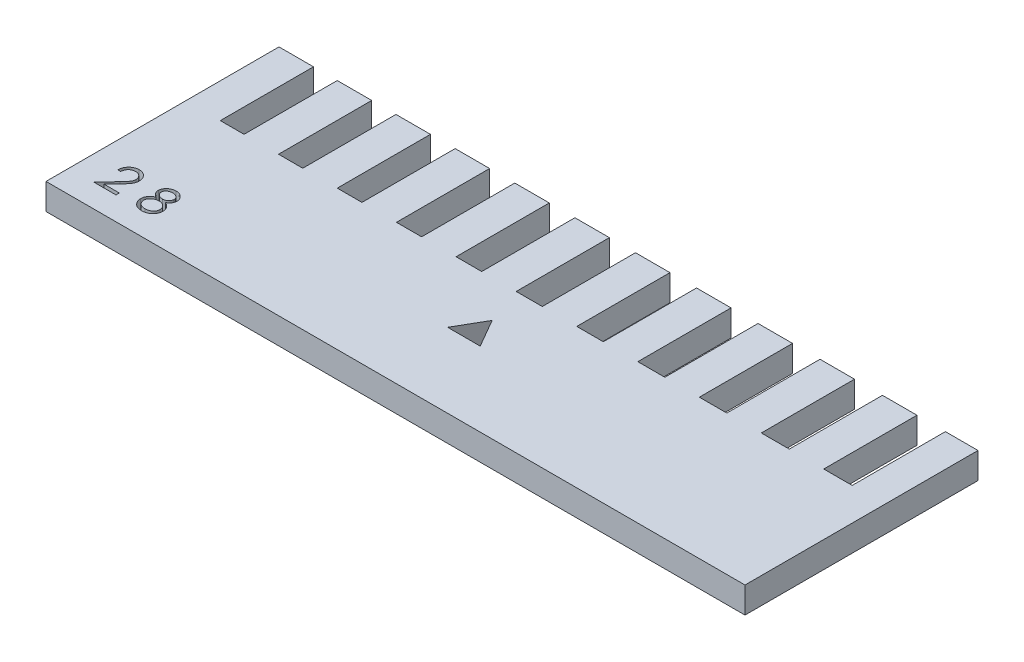
from build123d import *

# Parameters (mm, degrees)
SKETCH1_W           = 75
SKETCH1_H           = 25
BOSS_EXTRUDE1_DEPTH = 2.8
SKETCH2_W           = 2.55
SKETCH2_H           = 10
SKETCH2_W_2         = 2.6
SKETCH2_W_3         = 2.65
SKETCH2_W_4         = 2.7
SKETCH2_W_5         = 2.75
SKETCH2_W_6         = 2.8
SKETCH2_W_7         = 2.85
SKETCH2_W_8         = 2.9
SKETCH2_W_9         = 2.95
SKETCH2_W_10        = 3
SKETCH2_W_11        = 3.05
CUT_EXTRUDE1_DEPTH  = 3.8
CUT_EXTRUDE2_DEPTH  = 2.8
CUT_EXTRUDE4_DEPTH  = 2.8


with BuildPart() as part:
    # Sketch1 → Boss-Extrude1 (new body)
    with BuildSketch(Plane(origin=(0, 0, 0), x_dir=(1, 0, 0), z_dir=(0, 1, 0))):
        with Locations((37.5, 12.5)):
            Rectangle(SKETCH1_W, SKETCH1_H)
    extrude(amount=BOSS_EXTRUDE1_DEPTH)

    # Sketch2 → Cut-Extrude1 (cut, through all)
    with BuildSketch(Plane(origin=(0, 2.8, 0), x_dir=(1, 0, 0), z_dir=(0, 1, 0))):
        with Locations((4.975, 20)):
            Rectangle(SKETCH2_W, SKETCH2_H)
        with Locations((11.25, 20)):
            Rectangle(SKETCH2_W_2, SKETCH2_H)
        with Locations((17.575, 20)):
            Rectangle(SKETCH2_W_3, SKETCH2_H)
        with Locations((23.95, 20)):
            Rectangle(SKETCH2_W_4, SKETCH2_H)
        with Locations((30.375, 20)):
            Rectangle(SKETCH2_W_5, SKETCH2_H)
        with Locations((36.85, 20)):
            Rectangle(SKETCH2_W_6, SKETCH2_H)
        with Locations((43.375, 20)):
            Rectangle(SKETCH2_W_7, SKETCH2_H)
        with Locations((49.95, 20)):
            Rectangle(SKETCH2_W_8, SKETCH2_H)
        with Locations((56.575, 20)):
            Rectangle(SKETCH2_W_9, SKETCH2_H)
        with Locations((63.25, 20)):
            Rectangle(SKETCH2_W_10, SKETCH2_H)
        with Locations((69.975, 20)):
            Rectangle(SKETCH2_W_11, SKETCH2_H)
    extrude(amount=-CUT_EXTRUDE1_DEPTH, mode=Mode.SUBTRACT)

    # Sketch3 → Cut-Extrude2 (cut)
    with BuildSketch(Plane(origin=(0, 2.8, 0), x_dir=(1, 0, 0), z_dir=(0, 1, 0))):
        Polygon((36.85, 11.020725942), (35.1, 7.989637029), (38.6, 7.989637029), align=None)
    extrude(amount=-CUT_EXTRUDE2_DEPTH, mode=Mode.SUBTRACT)

    # Sketch5 → Cut-Extrude4 (cut)
    with BuildSketch(Plane(origin=(0, 2.8, 0), x_dir=(1, 0, 0), z_dir=(0, 1, 0))):
        with BuildLine():
            Line((3.083333333, 4.923076923), (2.769230769, 4.923076923))
            add(Edge.make_bspline(
                [(2.769230769, 4.923076923), (2.771277922, 4.964747811), (2.775298476, 5.046588325), (2.794126766, 5.165912232), (2.821067643, 5.279967031), (2.859159097, 5.387836945), (2.906465375, 5.490475752), (2.963195402, 5.587475767), (3.030389252, 5.678466956), (3.106595986, 5.762605799), (3.189364626, 5.83979337), (3.278670565, 5.906448613), (3.372515592, 5.962766284), (3.470614991, 6.009847526), (3.574075555, 6.045187372), (3.681958413, 6.071409012), (3.794737549, 6.087185357), (3.871577571, 6.088881143), (3.910657051, 6.08974359)],
                knots=[0, 0, 0, 0, 1.10065271, 2.161652631, 3.183658789, 4.190468796, 5.17591951, 6.163126047, 7.15150782, 8.156236427, 9.156009102, 10.134482811, 11.092018607, 12.041330605, 13.001268258, 13.972401359, 14.968799086, 16, 16, 16, 16], degree=3))
            add(Edge.make_bspline(
                [(3.910657051, 6.08974359), (3.949035125, 6.088845133), (4.02444667, 6.087079698), (4.134508684, 6.071918669), (4.239285979, 6.048173078), (4.338573745, 6.014857661), (4.43157981, 5.970073234), (4.519002855, 5.916275695), (4.601883665, 5.854055864), (4.676490449, 5.78080205), (4.744998528, 5.702599666), (4.804100783, 5.619111762), (4.854713947, 5.532882477), (4.896901627, 5.443254275), (4.927957766, 5.349383247), (4.951535974, 5.252636044), (4.964863387, 5.152011233), (4.966908811, 5.083904677), (4.967948718, 5.049278846)],
                knots=[0, 0, 0, 0, 1.111607364, 2.184268762, 3.212621178, 4.221274766, 5.211760367, 6.196651075, 7.1921475, 8.207485113, 9.220403448, 10.201281604, 11.166441695, 12.114753415, 13.065576456, 14.026450734, 14.996634279, 16, 16, 16, 16], degree=3))
            add(Edge.make_bspline(
                [(4.967948718, 5.049278846), (4.966255455, 5.000531012), (4.962898644, 4.903890798), (4.934184267, 4.761875935), (4.889337756, 4.624282516), (4.835340399, 4.513545214), (4.780867955, 4.42431172), (4.731780448, 4.350843015), (4.674315637, 4.271737547), (4.607637139, 4.18726021), (4.533124266, 4.096749304), (4.450102103, 4.000259509), (4.357978621, 3.898787739), (4.29332012, 3.829482138), (4.259815705, 3.793569712)],
                knots=[0, 0, 0, 0, 1.184426356, 2.348067706, 3.509069118, 4.696110526, 5.333549288, 6.050745305, 6.844228056, 7.710549037, 8.667450064, 9.695053472, 10.805634456, 12, 12, 12, 12], degree=3))
            Line((4.259815705, 3.793569712), (3.384114583, 2.858974359))
            Line((3.384114583, 2.858974359), (5.012820513, 2.858974359))
            Line((5.012820513, 2.858974359), (5.012820513, 2.5))
            Line((5.012820513, 2.5), (2.634615385, 2.5))
            Line((2.634615385, 2.5), (3.991987179, 3.948517628))
            add(Edge.make_bspline(
                [(3.991987179, 3.948517628), (4.025035066, 3.983015935), (4.088513293, 4.049280121), (4.17829587, 4.146023081), (4.258934859, 4.235772622), (4.330952251, 4.318359171), (4.392785757, 4.394990738), (4.447657989, 4.463185442), (4.49162358, 4.525939892), (4.539338975, 4.598680506), (4.585552957, 4.687492823), (4.625265313, 4.796026513), (4.649480161, 4.907753765), (4.652384997, 4.983255802), (4.653846154, 5.021233974)],
                knots=[0, 0, 0, 0, 1.329631726, 2.553950428, 3.673215718, 4.687767853, 5.603093632, 6.413772471, 7.123043292, 7.734684054, 8.834405432, 9.900288307, 10.943827018, 12, 12, 12, 12], degree=3))
            add(Edge.make_bspline(
                [(4.653846154, 5.021233974), (4.653210412, 5.045115373), (4.651957486, 5.092181023), (4.640899788, 5.161186782), (4.624189282, 5.227751596), (4.600244024, 5.292080215), (4.568637284, 5.353525867), (4.530163904, 5.412163347), (4.48577384, 5.468852313), (4.434422571, 5.522005611), (4.378011051, 5.570686816), (4.318416802, 5.613810902), (4.255366698, 5.649850012), (4.189126575, 5.679393509), (4.119881106, 5.702568891), (4.047496361, 5.71862747), (3.972172345, 5.728709954), (3.920738849, 5.730074126), (3.89453125, 5.730769231)],
                knots=[0, 0, 0, 0, 0.991446411, 1.95395049, 2.89581595, 3.838931463, 4.798493298, 5.75982156, 6.748411868, 7.785213223, 8.824556874, 9.840280684, 10.836137867, 11.835679398, 12.848801643, 13.863922112, 14.911575587, 16, 16, 16, 16], degree=3))
            add(Edge.make_bspline(
                [(3.89453125, 5.730769231), (3.867160417, 5.730054199), (3.813408621, 5.728649993), (3.734489588, 5.718827329), (3.659203811, 5.701881489), (3.587361908, 5.678704814), (3.518842322, 5.649246266), (3.453978278, 5.612554521), (3.392915389, 5.568771028), (3.335538865, 5.519130471), (3.282674886, 5.46386287), (3.23622801, 5.402252907), (3.195643996, 5.335425492), (3.160234763, 5.263560941), (3.131479073, 5.186007161), (3.109505922, 5.103039456), (3.092119075, 5.015018075), (3.086310555, 4.95423299), (3.083333333, 4.923076923)],
                knots=[0, 0, 0, 0, 1.031018746, 2.02475058, 2.990194455, 3.934040569, 4.864654155, 5.795059489, 6.735614925, 7.690564532, 8.649604399, 9.611025574, 10.590972636, 11.591080095, 12.624614302, 13.701020113, 14.821632451, 16, 16, 16, 16], degree=3))
        make_face()
        with BuildLine():
            add(Edge.make_bspline(
                [(8.374699519, 4.449819712), (8.403348066, 4.434881756), (8.459222301, 4.405747753), (8.538799509, 4.358836925), (8.61152451, 4.30939596), (8.679415072, 4.259760101), (8.741278423, 4.208028449), (8.796422836, 4.153995293), (8.846210456, 4.099009348), (8.88963724, 4.042139508), (8.927834077, 3.983536859), (8.960846212, 3.923047586), (8.989063415, 3.860804252), (9.011426353, 3.796127422), (9.029848145, 3.72996716), (9.04252375, 3.661469178), (9.049340668, 3.591084837), (9.050629481, 3.543516536), (9.051282051, 3.51943109)],
                knots=[0, 0, 0, 0, 1.272397273, 2.481599622, 3.635517121, 4.734568067, 5.792894095, 6.808321871, 7.773003508, 8.711915296, 9.623354172, 10.525449501, 11.423591555, 12.311487226, 13.218079475, 14.126165749, 15.051214107, 16, 16, 16, 16], degree=3))
            add(Edge.make_bspline(
                [(9.051282051, 3.51943109), (9.050510631, 3.485733357), (9.0489837, 3.4190329), (9.035683716, 3.320586789), (9.015770738, 3.224975007), (8.986691225, 3.132218516), (8.948977834, 3.042829143), (8.902500998, 2.956730369), (8.849889793, 2.87251106), (8.807637554, 2.820691659), (8.786258013, 2.794471154)],
                knots=[0, 0, 0, 0, 1.025265484, 2.029385089, 3.018602448, 3.995076438, 4.983346944, 5.966715145, 6.97116228, 8, 8, 8, 8], degree=3))
            add(Edge.make_bspline(
                [(8.786258013, 2.794471154), (8.758421539, 2.76387738), (8.703092573, 2.703067887), (8.608309645, 2.624117077), (8.504287762, 2.557767683), (8.391429429, 2.503695788), (8.270036327, 2.461609929), (8.140134323, 2.431367412), (8.00147017, 2.414044982), (7.906164699, 2.411540993), (7.857271635, 2.41025641)],
                knots=[0, 0, 0, 0, 0.954267603, 1.896743057, 2.838368354, 3.796610408, 4.779680527, 5.799409237, 6.871065594, 8, 8, 8, 8], degree=3))
            add(Edge.make_bspline(
                [(7.857271635, 2.41025641), (7.810258246, 2.411408888), (7.718774967, 2.413651493), (7.585617089, 2.428845925), (7.46149402, 2.455473792), (7.345684051, 2.491918401), (7.238885358, 2.539328629), (7.141402257, 2.598337038), (7.051828285, 2.66656848), (6.972881811, 2.745982558), (6.902793367, 2.831040431), (6.841225314, 2.91879204), (6.790051236, 3.009245398), (6.74672414, 3.101051765), (6.713556118, 3.195497919), (6.690583907, 3.292097932), (6.675994593, 3.390683075), (6.674053458, 3.457214728), (6.673076923, 3.490685096)],
                knots=[0, 0, 0, 0, 1.256902934, 2.445805442, 3.576955095, 4.645999104, 5.686449165, 6.692658513, 7.68621702, 8.689161843, 9.678783111, 10.630372946, 11.551080876, 12.453998257, 13.34127905, 14.221779781, 15.105423033, 16, 16, 16, 16], degree=3))
            add(Edge.make_bspline(
                [(6.673076923, 3.490685096), (6.673654804, 3.515244288), (6.674796901, 3.56378192), (6.682701749, 3.635491248), (6.695410211, 3.705287383), (6.712669667, 3.773428127), (6.736060694, 3.839417399), (6.764302827, 3.903567873), (6.797234779, 3.965951972), (6.835315944, 4.026910853), (6.879617968, 4.085590365), (6.929781618, 4.14298636), (6.986809487, 4.198208227), (7.050067146, 4.251930652), (7.118831685, 4.305106626), (7.194889216, 4.354862354), (7.276223484, 4.404720319), (7.334028889, 4.434528645), (7.363681891, 4.449819712)],
                knots=[0, 0, 0, 0, 0.941657376, 1.861047343, 2.762797495, 3.66048619, 4.553285746, 5.444104102, 6.34607688, 7.256116206, 8.197091036, 9.162375105, 10.176350973, 11.237807142, 12.343728897, 13.50695164, 14.721116704, 16, 16, 16, 16], degree=3))
            add(Edge.make_bspline(
                [(7.363681891, 4.449819712), (7.323090516, 4.47195448), (7.244494253, 4.514813588), (7.140424812, 4.593560394), (7.051034189, 4.678848209), (6.978779471, 4.772478003), (6.921907243, 4.871524878), (6.882888639, 4.97536913), (6.856492155, 5.082085244), (6.853877328, 5.15499144), (6.852564103, 5.191606571)],
                knots=[0, 0, 0, 0, 1.166880483, 2.259407225, 3.286803203, 4.280235371, 5.237608625, 6.161067461, 7.076446754, 8, 8, 8, 8], degree=3))
            add(Edge.make_bspline(
                [(6.852564103, 5.191606571), (6.854199527, 5.228904129), (6.857487014, 5.303878726), (6.884070335, 5.415484849), (6.927390401, 5.525101414), (6.986311398, 5.632197127), (7.059698615, 5.733147342), (7.14774516, 5.823688288), (7.248348457, 5.90299977), (7.361006324, 5.969575943), (7.48224256, 6.023759602), (7.610158284, 6.061138025), (7.742524777, 6.085574141), (7.832622496, 6.088340796), (7.878305288, 6.08974359)],
                knots=[0, 0, 0, 0, 0.888701115, 1.786444228, 2.72001202, 3.692817113, 4.693886446, 5.687152267, 6.695133018, 7.739871481, 8.800368666, 9.853104506, 10.91144658, 12, 12, 12, 12], degree=3))
            add(Edge.make_bspline(
                [(7.878305288, 6.08974359), (7.922809103, 6.088297247), (8.010565557, 6.085445223), (8.139560184, 6.061658345), (8.262985062, 6.021928825), (8.380414561, 5.968031602), (8.489746428, 5.901644661), (8.586348737, 5.821243787), (8.671681319, 5.731102236), (8.742265713, 5.630182633), (8.800428603, 5.523498439), (8.840929504, 5.411875918), (8.866881478, 5.297726859), (8.870154842, 5.220488855), (8.871794872, 5.181790865)],
                knots=[0, 0, 0, 0, 1.072916533, 2.115669174, 3.151510826, 4.193348718, 5.225979165, 6.227137561, 7.216255879, 8.211077061, 9.189680878, 10.138522389, 11.067357538, 12, 12, 12, 12], degree=3))
            add(Edge.make_bspline(
                [(8.871794872, 5.181790865), (8.870360311, 5.143814202), (8.867542916, 5.069230192), (8.843842976, 4.960503672), (8.803929662, 4.858681633), (8.7494355, 4.762608681), (8.678410012, 4.674027183), (8.591801279, 4.591810713), (8.490299801, 4.515283885), (8.414038915, 4.472097521), (8.374699519, 4.449819712)],
                knots=[0, 0, 0, 0, 0.975232327, 1.915300861, 2.843280834, 3.77672583, 4.742871857, 5.749627742, 6.839139064, 8, 8, 8, 8], degree=3))
        make_face()
        with BuildLine():
            add(Edge.make_bspline(
                [(7.860777244, 5.730769231), (7.836226438, 5.73011779), (7.788194327, 5.728843288), (7.717765655, 5.722184651), (7.650793288, 5.709231434), (7.586577487, 5.691992722), (7.525998675, 5.668704734), (7.468234121, 5.641309725), (7.414266931, 5.608003659), (7.363445628, 5.570642462), (7.317694853, 5.529549555), (7.277090302, 5.486735837), (7.243362188, 5.441360445), (7.214721078, 5.394552085), (7.193939561, 5.344921509), (7.178375257, 5.293990332), (7.167853865, 5.241114948), (7.167065475, 5.204978438), (7.166666667, 5.186698718)],
                knots=[0, 0, 0, 0, 1.203892937, 2.355340988, 3.463153438, 4.544400666, 5.610487187, 6.640501085, 7.674077295, 8.714426146, 9.728707835, 10.68524104, 11.601827946, 12.495867327, 13.368432065, 14.231010473, 15.105153427, 16, 16, 16, 16], degree=3))
            add(Edge.make_bspline(
                [(7.166666667, 5.186698718), (7.167354034, 5.168418208), (7.168712369, 5.132293295), (7.179217497, 5.078947429), (7.194874352, 5.026525793), (7.219525014, 4.976274882), (7.249091372, 4.926451522), (7.285582848, 4.878300936), (7.329071876, 4.831655552), (7.378099316, 4.78691211), (7.431510854, 4.745013347), (7.488094897, 4.708640166), (7.547141289, 4.678206055), (7.608043358, 4.652876651), (7.671421805, 4.633186713), (7.736888279, 4.619218067), (7.804453781, 4.61053607), (7.850234362, 4.609499049), (7.873397436, 4.608974359)],
                knots=[0, 0, 0, 0, 0.873023192, 1.725219244, 2.590779336, 3.480155217, 4.391973325, 5.357036234, 6.360879153, 7.436073238, 8.526419356, 9.601555421, 10.645666583, 11.697338044, 12.750135903, 13.812665442, 14.89329948, 16, 16, 16, 16], degree=3))
            add(Edge.make_bspline(
                [(7.873397436, 4.608974359), (7.90314754, 4.609847226), (7.962353907, 4.611584339), (8.049633239, 4.627735513), (8.134495883, 4.653141431), (8.216034788, 4.687901397), (8.292139373, 4.731529257), (8.359979441, 4.783762275), (8.418976334, 4.843394372), (8.468516944, 4.909497208), (8.506926791, 4.979848796), (8.536828599, 5.050449089), (8.554289814, 5.12205132), (8.556567381, 5.170018284), (8.557692308, 5.193709936)],
                knots=[0, 0, 0, 0, 1.076279235, 2.141928126, 3.20205304, 4.278698113, 5.344010996, 6.36967002, 7.368914609, 8.37248503, 9.349703398, 10.264243087, 11.142681841, 12, 12, 12, 12], degree=3))
            add(Edge.make_bspline(
                [(8.557692308, 5.193709936), (8.55716041, 5.210337972), (8.55610467, 5.24334224), (8.547404614, 5.292080605), (8.533028781, 5.339710189), (8.513565701, 5.386624459), (8.487955906, 5.432165191), (8.457591718, 5.477048279), (8.420707217, 5.520264043), (8.379310784, 5.562819592), (8.332365375, 5.602203615), (8.279961463, 5.636838326), (8.222367712, 5.666250682), (8.159582762, 5.690139437), (8.091837838, 5.708081787), (8.019444964, 5.721518134), (7.941800517, 5.729091246), (7.888370766, 5.730197771), (7.860777244, 5.730769231)],
                knots=[0, 0, 0, 0, 0.814439003, 1.616544685, 2.417341072, 3.248991801, 4.09997495, 4.973547432, 5.9003056, 6.880240646, 7.880314356, 8.896779544, 9.951930927, 11.043077905, 12.18215768, 13.381699519, 14.647792085, 16, 16, 16, 16], degree=3))
        make_face(mode=Mode.SUBTRACT)
        with BuildLine():
            add(Edge.make_bspline(
                [(7.881109776, 4.25), (7.84998399, 4.249446359), (7.788922794, 4.248360249), (7.699465865, 4.236270749), (7.6136127, 4.219441356), (7.531652764, 4.193910517), (7.453620667, 4.160714027), (7.379093984, 4.120779487), (7.308642855, 4.073574044), (7.243240128, 4.019697428), (7.183516799, 3.961637975), (7.131118499, 3.900175839), (7.086620978, 3.836453307), (7.050787727, 3.769661077), (7.021375995, 3.701213466), (7.002062118, 3.629405871), (6.989680407, 3.555618758), (6.988017775, 3.50545866), (6.987179487, 3.480168269)],
                knots=[0, 0, 0, 0, 1.140299081, 2.23698856, 3.303958914, 4.344563908, 5.37730929, 6.408454204, 7.439741482, 8.480804886, 9.510774543, 10.48932336, 11.43758569, 12.353841022, 13.263987381, 14.161954604, 15.073269652, 16, 16, 16, 16], degree=3))
            add(Edge.make_bspline(
                [(6.987179487, 3.480168269), (6.988542746, 3.448737363), (6.99124742, 3.38637918), (7.012704058, 3.294216108), (7.047139594, 3.204995054), (7.09516481, 3.119443101), (7.154632382, 3.039492995), (7.22775885, 2.969804219), (7.309999688, 2.90788274), (7.404137542, 2.857802207), (7.506966008, 2.817807352), (7.618457737, 2.790251389), (7.737012656, 2.772009939), (7.818872248, 2.770171758), (7.860777244, 2.769230769)],
                knots=[0, 0, 0, 0, 0.898778495, 1.783155532, 2.693654817, 3.627872908, 4.583023416, 5.533784346, 6.509005473, 7.520592997, 8.575161974, 9.658835044, 10.801527049, 12, 12, 12, 12], degree=3))
            add(Edge.make_bspline(
                [(7.860777244, 2.769230769), (7.893527612, 2.769859578), (7.95733583, 2.771084698), (8.050421779, 2.781898992), (8.138266328, 2.799048617), (8.220699126, 2.823992163), (8.298642966, 2.854442139), (8.37077632, 2.893614221), (8.438954847, 2.938166544), (8.49981897, 2.991024701), (8.555252179, 3.047504195), (8.603585471, 3.107294238), (8.645543023, 3.168769871), (8.678473978, 3.233320355), (8.704800232, 3.29970727), (8.723723787, 3.368542781), (8.735400002, 3.440038014), (8.736580898, 3.488537085), (8.737179487, 3.513120994)],
                knots=[0, 0, 0, 0, 1.224942928, 2.386581632, 3.501229538, 4.569074225, 5.605009692, 6.626002462, 7.634866581, 8.645888296, 9.63523824, 10.59253846, 11.518950513, 12.414518923, 13.29783783, 14.186679152, 15.080837789, 16, 16, 16, 16], degree=3))
            add(Edge.make_bspline(
                [(8.737179487, 3.513120994), (8.736273639, 3.536998334), (8.734487464, 3.584080279), (8.723150772, 3.653846806), (8.703234895, 3.72124962), (8.675907498, 3.787099626), (8.639526536, 3.850062576), (8.596681666, 3.911778748), (8.544987547, 3.970535192), (8.486574951, 4.026788288), (8.42291599, 4.078804025), (8.355248845, 4.124818464), (8.284094383, 4.16357058), (8.209603172, 4.195087075), (8.131940616, 4.219874545), (8.051163838, 4.23719054), (7.967178263, 4.248090143), (7.910123392, 4.249356189), (7.881109776, 4.25)],
                knots=[0, 0, 0, 0, 0.917430815, 1.809013306, 2.70690318, 3.612392954, 4.541220862, 5.495268465, 6.494511384, 7.542276156, 8.608045339, 9.649016899, 10.681629292, 11.715607085, 12.752076957, 13.808767841, 14.885711793, 16, 16, 16, 16], degree=3))
        make_face(mode=Mode.SUBTRACT)
    extrude(amount=-CUT_EXTRUDE4_DEPTH, mode=Mode.SUBTRACT)


solid = part.part
